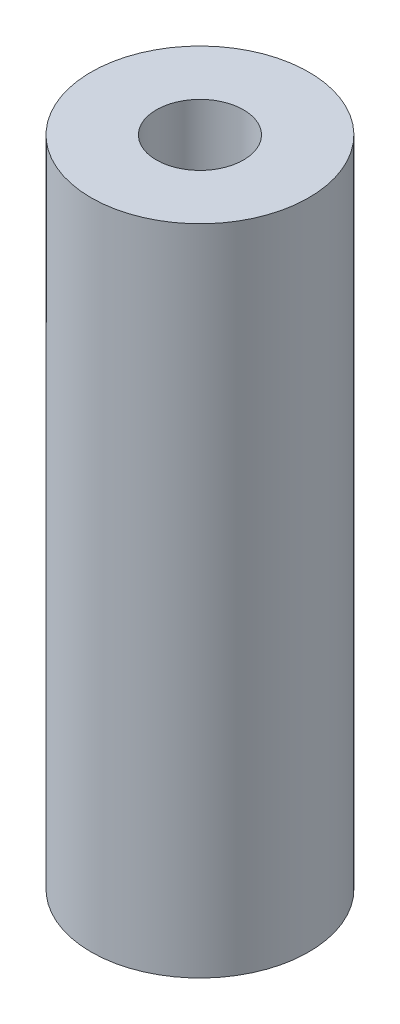
from build123d import *

# Parameters (mm, degrees)
SKETCH1_R           = 3.175
SKETCH1_R_2         = 1.27
BOSS_EXTRUDE1_DEPTH = 19.05


with BuildPart() as part:
    # Sketch1 → Boss-Extrude1 (new body)
    with BuildSketch(Plane(origin=(0, 0, 0), x_dir=(1, 0, 0), z_dir=(0, 1, 0))):
        Circle(SKETCH1_R)
        Circle(SKETCH1_R_2, mode=Mode.SUBTRACT)
    extrude(amount=BOSS_EXTRUDE1_DEPTH)


solid = part.part
